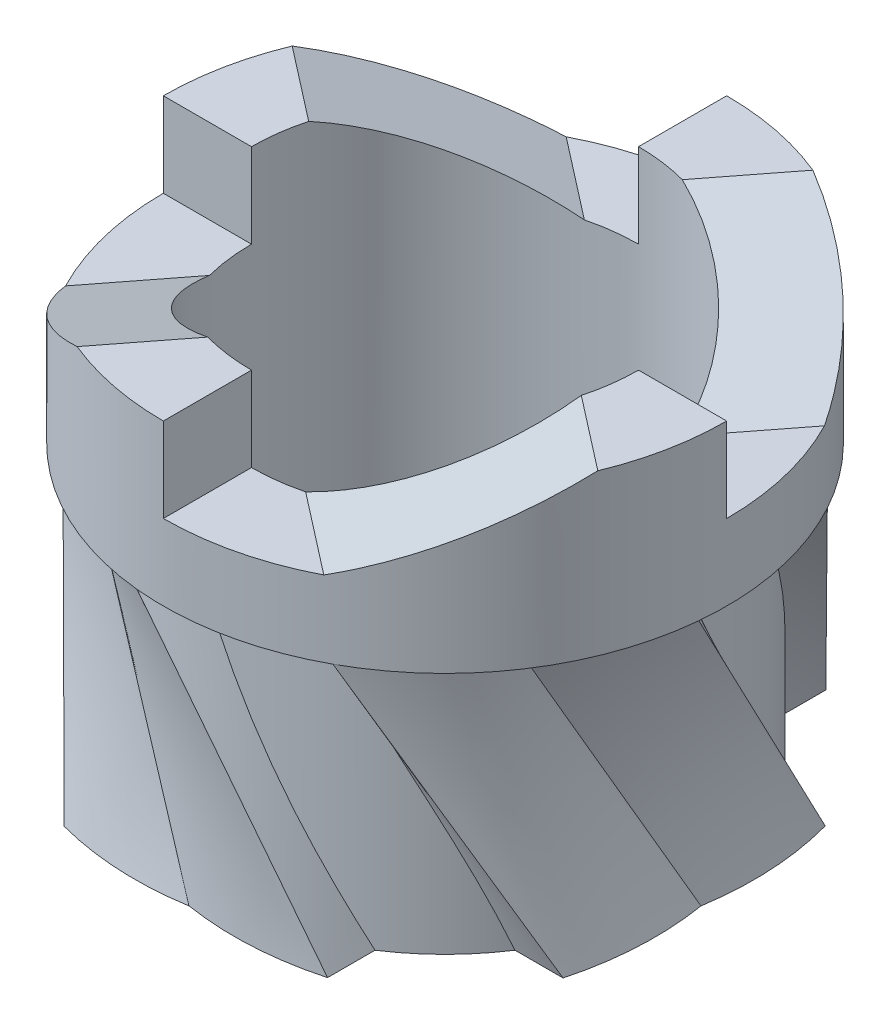
from build123d import *

# Parameters (mm, degrees)
SKETCH1_R           = 15
BOSS_EXTRUDE1_DEPTH = 17
CIRPATTERN1_COUNT   = 4
BOSS_EXTRUDE3_DEPTH = 10
SKETCH12_W          = 14.047466192
SKETCH12_H          = 9.954867113
CUT_EXTRUDE2_DEPTH  = 3
CUT_EXTRUDE3_DEPTH  = 9
CIRPATTERN11_COUNT  = 4
SKETCH14_R          = 12.072799678
CUT_EXTRUDE4_DEPTH  = 24


with BuildPart() as part:
    # Sketch1 → Boss-Extrude1 (new body)
    with BuildSketch(Plane(origin=(0, 0, 0), x_dir=(1, 0, 0), z_dir=(0, 1, 0))):
        Circle(SKETCH1_R)
    extrude(amount=BOSS_EXTRUDE1_DEPTH)

    # Sketch7 → Loft3 section 0
    with BuildSketch(Plane(origin=(0, 17, 0), x_dir=(1, 0, 0), z_dir=(0, 1, 0))):
        with BuildLine():
            Line((-15.419212864, -8.429185203), (-13.785295759, -5.913173499))
            Line((-13.785295759, -5.913173499), (-0.036662397, -14.999955196))
            Line((-0.036662397, -14.999955196), (-1.670579502, -17.515966899))
            ThreePointArc((-1.670579502, -17.515966899), (-5.449846484, -15.759052669), (-8.767392344, -13.236455593))
            ThreePointArc((-8.767392344, -13.236455593), (-12.350066375, -11.188104454), (-15.419212864, -8.429185203))
        make_face()
    # Sketch2 → Loft3 section 1
    with BuildSketch(Plane.XZ):
        with BuildLine():
            Line((8.1969132, 15.523322087), (8.1969132, 12.562269461))
            Line((8.1969132, 12.562269461), (-8.1969132, 12.562269461))
            Line((-8.1969132, 12.562269461), (-8.1969132, 15.562269461))
            ThreePointArc((-8.1969132, 15.562269461), (-4.120295252, 16.204516854), (0, 15.971144539))
            ThreePointArc((0, 15.971144539), (4.122381552, 16.185154095), (8.1969132, 15.523322087))
        make_face()
    loft3 = loft()

    # CirPattern1: Loft3 ×4 about axis
    cirpattern1_axis = Axis((0, 0, 0), (0, -1, 0))
    for i in range(1, CIRPATTERN1_COUNT):
        add(loft3.rotate(cirpattern1_axis, i * 360 / CIRPATTERN1_COUNT))

    # Sketch8 → Boss-Extrude3 (add)
    with BuildSketch(Plane(origin=(0, 17, 0), x_dir=(1, 0, 0), z_dir=(0, 1, 0))):
        with BuildLine():
            Line((17.572799678, 0), (12.072799678, 0))
            ThreePointArc((12.072799678, 0), (8.536758521, -8.536758521), (0, -12.072799678))
            Line((0, -12.072799678), (0, -17.572799678))
            ThreePointArc((0, -17.572799678), (12.425845817, -12.425845817), (17.572799678, 0))
        make_face()
    boss_extrude3 = extrude(amount=BOSS_EXTRUDE3_DEPTH)

    # Sketch12 → Cut-Extrude2 (cut)
    with BuildSketch(Plane.ZY):
        with Locations((15, 26.710348928)):
            Rectangle(SKETCH12_W, SKETCH12_H)
    cut_extrude2 = extrude(amount=-CUT_EXTRUDE2_DEPTH, mode=Mode.SUBTRACT)

    # Sketch13 → Cut-Extrude3 (cut)
    with BuildSketch(Plane(origin=(7.536399839, 0, 5.847061058), x_dir=(-0.612987567, 0, 0.790092553), z_dir=(-0.790092553, 0, -0.612987567))):
        Polygon((-4.655510065, 27), (7.400476101, 21.732915371), (11.841354417, 21.732915371), (11.841354417, 27), align=None)
    cut_extrude3 = extrude(amount=-CUT_EXTRUDE3_DEPTH, mode=Mode.SUBTRACT)

    # CirPattern11: Boss-Extrude3, Cut-Extrude2, Cut-Extrude3 ×4 about axis
    cirpattern11_axis = Axis((0, 0, 0), (0, 1, 0))
    for i in range(1, CIRPATTERN11_COUNT):
        add(boss_extrude3.rotate(cirpattern11_axis, i * 360 / CIRPATTERN11_COUNT))
        add(cut_extrude2.rotate(cirpattern11_axis, i * 360 / CIRPATTERN11_COUNT), mode=Mode.SUBTRACT)
        add(cut_extrude3.rotate(cirpattern11_axis, i * 360 / CIRPATTERN11_COUNT), mode=Mode.SUBTRACT)

    # Sketch14 → Cut-Extrude4 (cut)
    with BuildSketch(Plane(origin=(0, 17, 0), x_dir=(1, 0, 0), z_dir=(0, 1, 0))):
        Circle(SKETCH14_R)
    extrude(amount=-CUT_EXTRUDE4_DEPTH, mode=Mode.SUBTRACT)


solid = part.part
